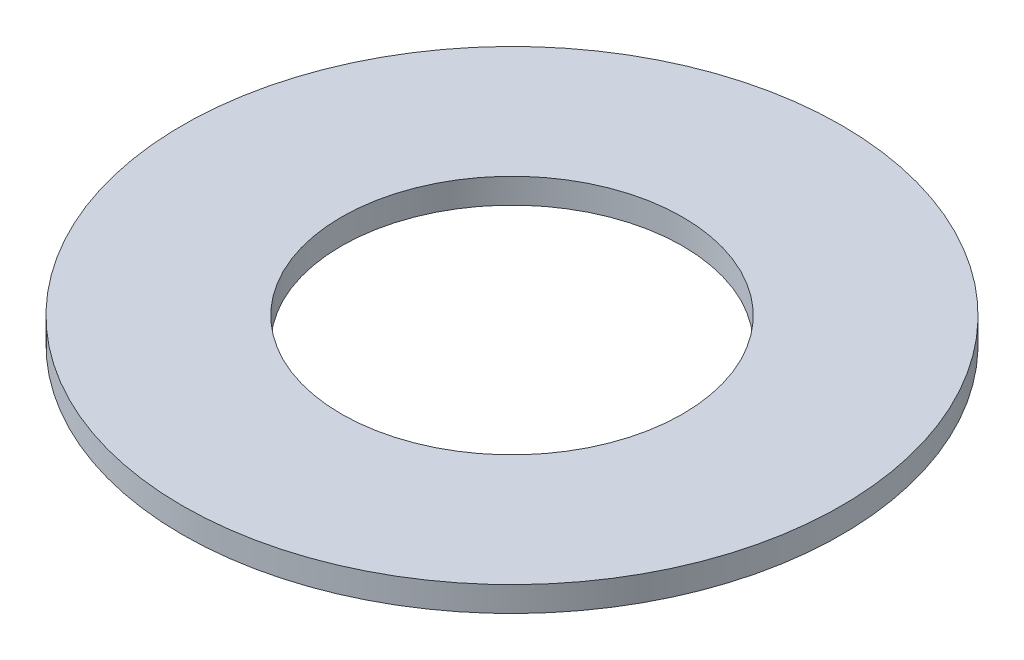
from build123d import *

# Parameters (mm, degrees)
SKETCH1_R           = 44.45
BOSS_EXTRUDE1_DEPTH = 3.3782
SKETCH5_R           = 23.0124
CUT_EXTRUDE1_DEPTH  = 4.3782


with BuildPart() as part:
    # Sketch1 → Boss-Extrude1 (new body)
    with BuildSketch(Plane(origin=(0, 0, 0), x_dir=(1, 0, 0), z_dir=(0, 1, 0))):
        Circle(SKETCH1_R)
    extrude(amount=BOSS_EXTRUDE1_DEPTH)

    # Sketch5 → Cut-Extrude1 (cut, through all)
    with BuildSketch(Plane(origin=(0, 3.3782, 0), x_dir=(-1, 0, 0), z_dir=(0, 1, 0))):
        Circle(SKETCH5_R)
    extrude(amount=-CUT_EXTRUDE1_DEPTH, mode=Mode.SUBTRACT)


solid = part.part
